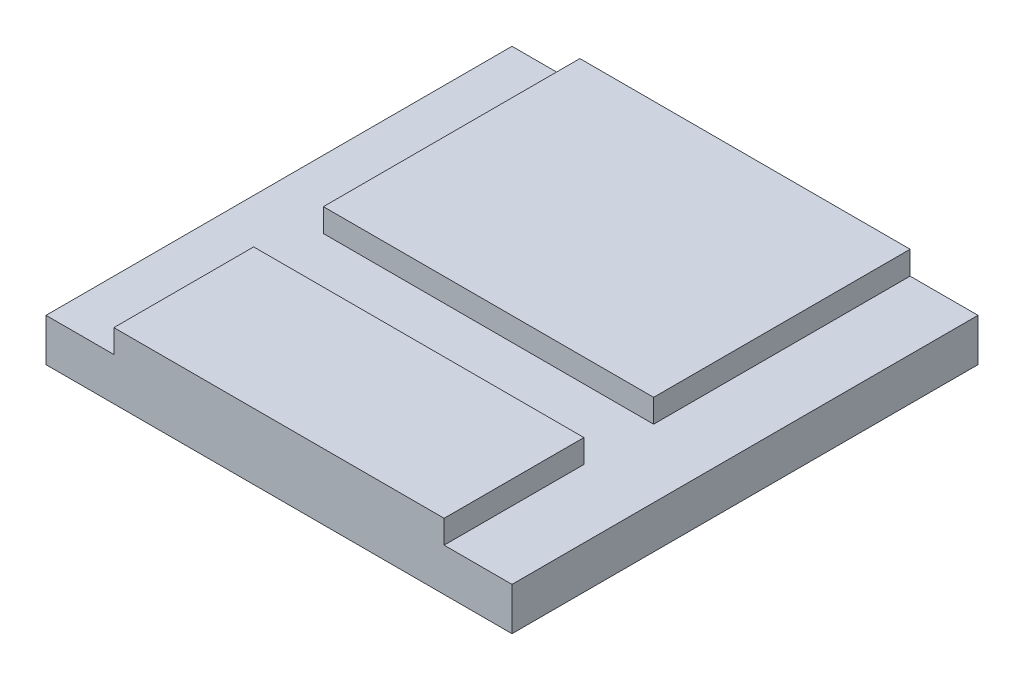
from build123d import *

# Parameters (mm, degrees)
SKETCH1_W           = 127
SKETCH1_H           = 127
BOSS_EXTRUDE1_DEPTH = 18
SKETCH2_W           = 127
SKETCH2_H           = 19
CUT_EXTRUDE1_DEPTH  = 6.35
SKETCH3_W           = 18.5
SKETCH3_H           = 127
CUT_EXTRUDE2_DEPTH  = 6.35


with BuildPart() as part:
    # Sketch1 → Boss-Extrude1 (new body)
    with BuildSketch(Plane(origin=(0, 0, 0), x_dir=(1, 0, 0), z_dir=(0, 1, 0))):
        Rectangle(SKETCH1_W, SKETCH1_H)
    extrude(amount=BOSS_EXTRUDE1_DEPTH)

    # Sketch2 → Cut-Extrude1 (cut)
    with BuildSketch(Plane(origin=(0, 18, 0), x_dir=(1, 0, 0), z_dir=(0, 1, 0))):
        with Locations((0, -15.9)):
            Rectangle(SKETCH2_W, SKETCH2_H)
    extrude(amount=-CUT_EXTRUDE1_DEPTH, mode=Mode.SUBTRACT)

    # Sketch3 → Cut-Extrude2 (cut)
    with BuildSketch(Plane(origin=(0, 18, 0), x_dir=(1, 0, 0), z_dir=(0, 1, 0))):
        with Locations((54.25, 0)):
            Rectangle(SKETCH3_W, SKETCH3_H)
        with Locations((-54.25, 0)):
            Rectangle(SKETCH3_W, SKETCH3_H)
    extrude(amount=-CUT_EXTRUDE2_DEPTH, mode=Mode.SUBTRACT)


solid = part.part
